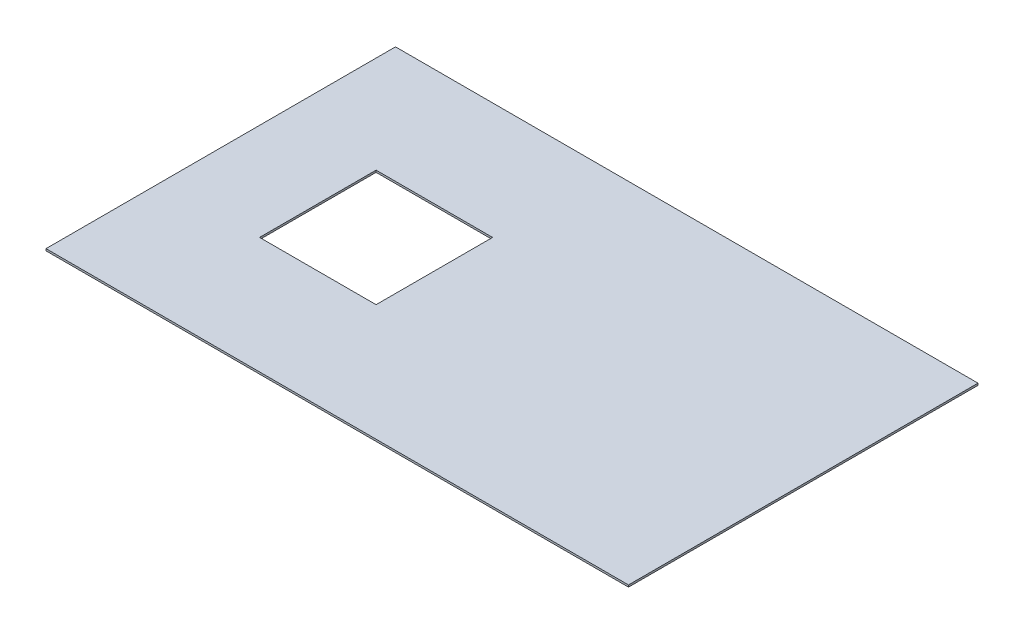
from build123d import *

# Parameters (mm, degrees)
SKETCH1_W          = 3000
SKETCH1_H          = 1800
EXTRUDE2_DEPTH     = 10
SKETCH2_W          = 600
SKETCH2_H          = 600
CUT_EXTRUDE1_DEPTH = 10


with BuildPart() as part:
    # Sketch1 → Extrude2 (new body)
    with BuildSketch(Plane(origin=(0, 0, 0), x_dir=(1, 0, 0), z_dir=(0, 1, 0))):
        with Locations((-1500, 900)):
            Rectangle(SKETCH1_W, SKETCH1_H)
    extrude(amount=EXTRUDE2_DEPTH)

    # Sketch2 → Cut-Extrude1 (cut)
    with BuildSketch(Plane(origin=(0, 10, 0), x_dir=(-1, 0, 0), z_dir=(0, 1, 0))):
        with Locations((2200, -900)):
            Rectangle(SKETCH2_W, SKETCH2_H)
    extrude(amount=-CUT_EXTRUDE1_DEPTH, mode=Mode.SUBTRACT)


solid = part.part
